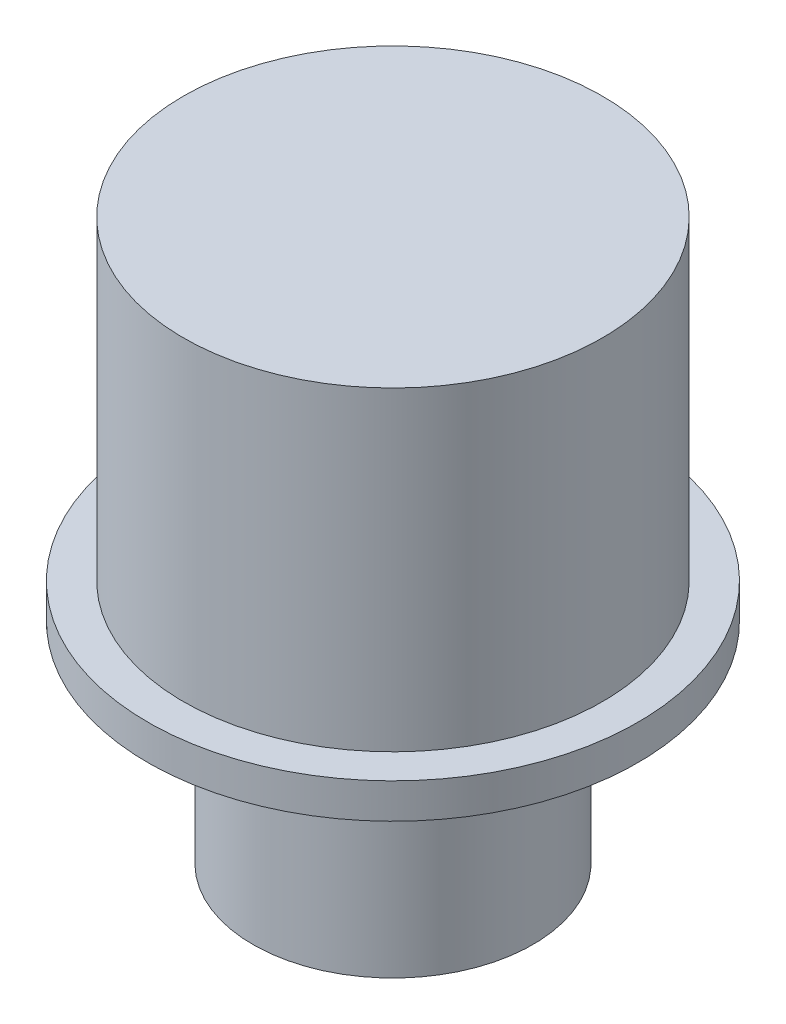
from build123d import *


with BuildPart() as part:
    # Sketch1 → Revolve1 (revolve)
    with BuildSketch(Plane.XY):
        Polygon((0, 0), (12.7, 0), (12.7, 19.05), (22.225, 19.05), (22.225, 22.225), (19, 22.225), (19, 50.8), (0, 50.8), align=None)
    revolve(axis=Axis((0, 50.8, 0), (0, -1, 0)))


solid = part.part
